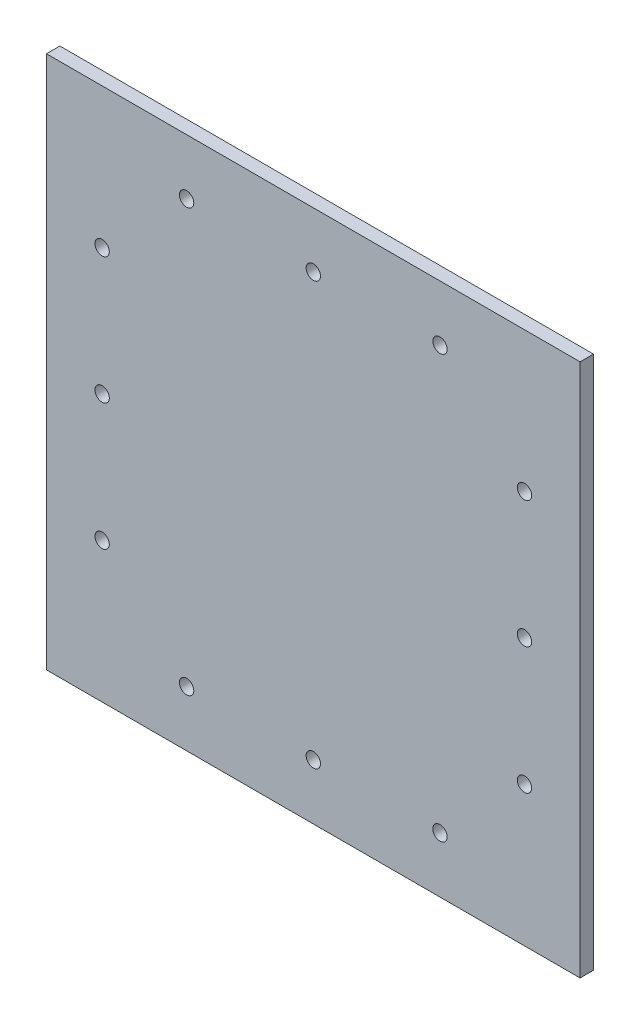
from build123d import *

# Parameters (mm, degrees)
SKETCH1_W           = 126.35
SKETCH1_H           = 126.35
BOSS_EXTRUDE1_DEPTH = 3.175
SKETCH2_R           = 1.7
CUT_EXTRUDE1_DEPTH  = 7


with BuildPart() as part:
    # Sketch1 → Boss-Extrude1 (new body)
    with BuildSketch(Plane.XY):
        Rectangle(SKETCH1_W, SKETCH1_H)
    extrude(amount=BOSS_EXTRUDE1_DEPTH)

    # Sketch2 → Cut-Extrude1 (cut)
    with BuildSketch(Plane(origin=(-17.047760395, -31.681970197, 0), x_dir=(-1, 0, 0), z_dir=(0, 0, -1))):
        with Locations((-17.047760395, -18.318029803)):
            Circle(SKETCH2_R)
        with Locations((12.952239605, -18.318029803)):
            Circle(SKETCH2_R)
        with Locations((-47.047760395, -18.318029803)):
            Circle(SKETCH2_R)
        with Locations((-67.047760395, 61.681970197)):
            Circle(SKETCH2_R)
        with Locations((-67.047760395, 31.681970197)):
            Circle(SKETCH2_R)
        with Locations((-67.047760395, 1.681970197)):
            Circle(SKETCH2_R)
        with Locations((12.952239605, 81.681970197)):
            Circle(SKETCH2_R)
        with Locations((-17.047760395, 81.681970197)):
            Circle(SKETCH2_R)
        with Locations((-47.047760395, 81.681970197)):
            Circle(SKETCH2_R)
        with Locations((32.952239605, 1.681970197)):
            Circle(SKETCH2_R)
        with Locations((32.952239605, 31.681970197)):
            Circle(SKETCH2_R)
        with Locations((32.952239605, 61.681970197)):
            Circle(SKETCH2_R)
    extrude(amount=-CUT_EXTRUDE1_DEPTH, mode=Mode.SUBTRACT)


solid = part.part
